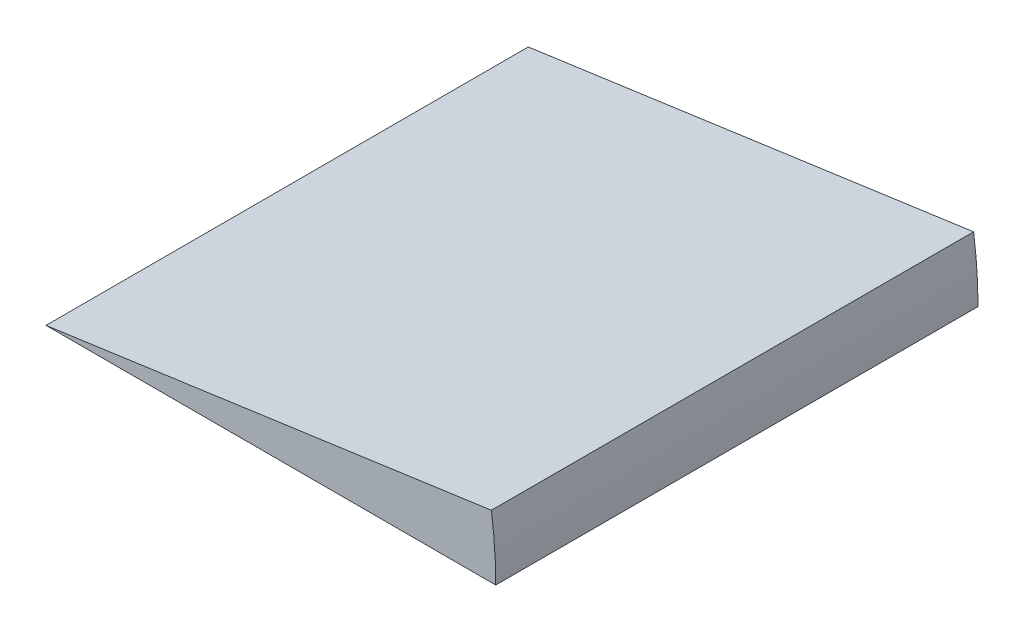
from build123d import *

# Parameters (mm, degrees)
SKETCH1_W      = 108.966
SKETCH1_H      = 116.84
REVOLVE1_ANGLE = 8


with BuildPart() as part:
    # Sketch1 → Revolve1 (revolve)
    with BuildSketch(Plane(origin=(0, 0, 0), x_dir=(1, 0, 0), z_dir=(0, 1, 0))):
        Rectangle(SKETCH1_W, SKETCH1_H)
    revolve(axis=Axis((-54.483, 0, 58.42), (0, 0, 1)), revolution_arc=REVOLVE1_ANGLE)


solid = part.part
